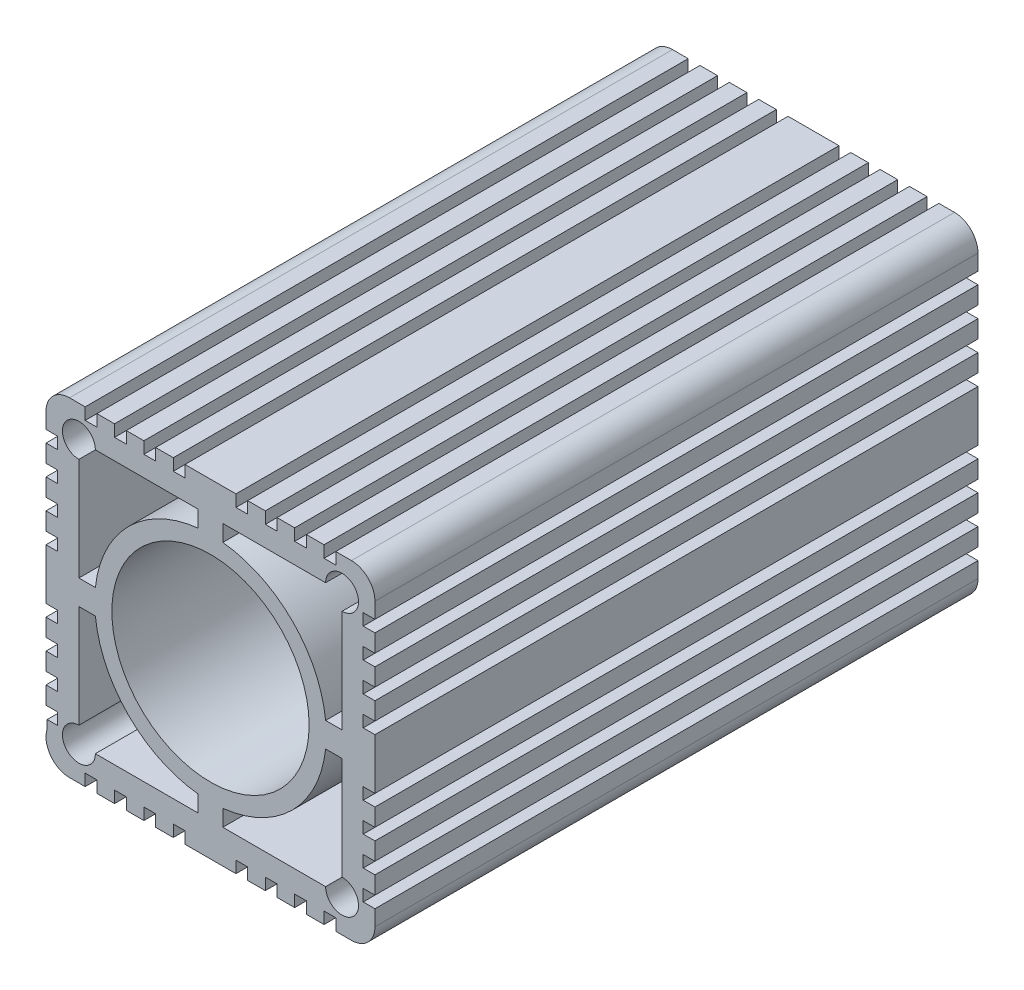
from build123d import *

# Parameters (mm, degrees)
SKETCH3_R           = 8.996543211
BOSS_EXTRUDE1_DEPTH = 55
SKETCH4_W           = 25.72553188
SKETCH4_H           = 15
BOSS_EXTRUDE2_DEPTH = 3
SKETCH5_R           = 1.5
CUT_EXTRUDE1_DEPTH  = 3.5


with BuildPart() as part:
    # Sketch3 → Boss-Extrude1 (new body)
    with BuildSketch(Plane(origin=(0, 0, 0), x_dir=(-1, 0, 0), z_dir=(0, 0, 1))):
        with BuildLine():
            Line((-14.998808917, -10.28846037), (-13.927380346, -10.28846037))
            Line((-13.927380346, -10.28846037), (-13.927380346, -11.359888941))
            Line((-13.927380346, -11.359888941), (-14.998808917, -11.359888941))
            Line((-14.998808917, -11.359888941), (-14.998808917, -12.78846037))
            ThreePointArc((-14.998808917, -12.78846037), (-14.371180591, -14.303689187), (-12.855951774, -14.931317513))
            Line((-12.855951774, -14.931317513), (-11.427380346, -14.931317513))
            Line((-11.427380346, -14.931317513), (-11.427380346, -13.859888941))
            Line((-11.427380346, -13.859888941), (-10.355951774, -13.859888941))
            Line((-10.355951774, -13.859888941), (-10.355951774, -14.931317513))
            Line((-10.355951774, -14.931317513), (-8.748808917, -14.931317513))
            Line((-8.748808917, -14.931317513), (-8.748808917, -13.859888941))
            Line((-8.748808917, -13.859888941), (-7.677380346, -13.859888941))
            Line((-7.677380346, -13.859888941), (-7.677380346, -14.931317513))
            Line((-7.677380346, -14.931317513), (-6.070237488, -14.931317513))
            Line((-6.070237488, -14.931317513), (-6.070237488, -13.859888941))
            Line((-6.070237488, -13.859888941), (-4.998808917, -13.859888941))
            Line((-4.998808917, -13.859888941), (-4.998808917, -14.931317513))
            Line((-4.998808917, -14.931317513), (-3.39166606, -14.931317513))
            Line((-3.39166606, -14.931317513), (-3.39166606, -13.859888941))
            Line((-3.39166606, -13.859888941), (-2.320237488, -13.859888941))
            Line((-2.320237488, -13.859888941), (-2.320237488, -14.931317513))
            Line((-2.320237488, -14.931317513), (2.322619654, -14.931317513))
            Line((2.322619654, -14.931317513), (2.322619654, -13.859888941))
            Line((2.322619654, -13.859888941), (3.394048226, -13.859888941))
            Line((3.394048226, -13.859888941), (3.394048226, -14.931317513))
            Line((3.394048226, -14.931317513), (5.001191083, -14.931317513))
            Line((5.001191083, -14.931317513), (5.001191083, -13.859888941))
            Line((5.001191083, -13.859888941), (6.072619654, -13.859888941))
            Line((6.072619654, -13.859888941), (6.072619654, -14.931317513))
            Line((6.072619654, -14.931317513), (7.679762512, -14.931317513))
            Line((7.679762512, -14.931317513), (7.679762512, -13.859888941))
            Line((7.679762512, -13.859888941), (8.751191083, -13.859888941))
            Line((8.751191083, -13.859888941), (8.751191083, -14.931317513))
            Line((8.751191083, -14.931317513), (10.35833394, -14.931317513))
            Line((10.35833394, -14.931317513), (10.35833394, -13.859888941))
            Line((10.35833394, -13.859888941), (11.429762512, -13.859888941))
            Line((11.429762512, -13.859888941), (11.429762512, -14.931317513))
            Line((11.429762512, -14.931317513), (12.85833394, -14.931317513))
            ThreePointArc((12.85833394, -14.931317513), (14.373562757, -14.303689187), (15.001191083, -12.78846037))
            Line((15.001191083, -12.78846037), (15.001191083, -11.359888941))
            Line((15.001191083, -11.359888941), (13.929762512, -11.359888941))
            Line((13.929762512, -11.359888941), (13.929762512, -10.28846037))
            Line((13.929762512, -10.28846037), (15.001191083, -10.28846037))
            Line((15.001191083, -10.28846037), (15.001191083, -8.681317513))
            Line((15.001191083, -8.681317513), (13.929762512, -8.681317513))
            Line((13.929762512, -8.681317513), (13.929762512, -7.609888941))
            Line((13.929762512, -7.609888941), (15.001191083, -7.609888941))
            Line((15.001191083, -7.609888941), (15.001191083, -6.002746084))
            Line((15.001191083, -6.002746084), (13.929762512, -6.002746084))
            Line((13.929762512, -6.002746084), (13.929762512, -4.931317513))
            Line((13.929762512, -4.931317513), (15.001191083, -4.931317513))
            Line((15.001191083, -4.931317513), (15.001191083, -3.324174656))
            Line((15.001191083, -3.324174656), (13.929762512, -3.324174656))
            Line((13.929762512, -3.324174656), (13.929762512, -2.252746084))
            Line((13.929762512, -2.252746084), (15.001191083, -2.252746084))
            Line((15.001191083, -2.252746084), (15.001191083, 2.390111059))
            Line((15.001191083, 2.390111059), (13.929762512, 2.390111059))
            Line((13.929762512, 2.390111059), (13.929762512, 3.46153963))
            Line((13.929762512, 3.46153963), (15.001191083, 3.46153963))
            Line((15.001191083, 3.46153963), (15.001191083, 5.068682487))
            Line((15.001191083, 5.068682487), (13.929762512, 5.068682487))
            Line((13.929762512, 5.068682487), (13.929762512, 6.140111059))
            Line((13.929762512, 6.140111059), (15.001191083, 6.140111059))
            Line((15.001191083, 6.140111059), (15.001191083, 7.747253916))
            Line((15.001191083, 7.747253916), (13.929762512, 7.747253916))
            Line((13.929762512, 7.747253916), (13.929762512, 8.818682487))
            Line((13.929762512, 8.818682487), (15.001191083, 8.818682487))
            Line((15.001191083, 8.818682487), (15.001191083, 10.425825344))
            Line((15.001191083, 10.425825344), (13.929762512, 10.425825344))
            Line((13.929762512, 10.425825344), (13.929762512, 11.497253916))
            Line((13.929762512, 11.497253916), (14.894048226, 11.497253916))
            Line((14.894048226, 11.497253916), (14.894048226, 12.256718416))
            ThreePointArc((14.894048226, 12.256718416), (14.594081228, 14.182415209), (12.85833394, 15.068682487))
            Line((12.85833394, 15.068682487), (11.429762512, 15.068682487))
            Line((11.429762512, 15.068682487), (11.429762512, 13.997253916))
            Line((11.429762512, 13.997253916), (10.35833394, 13.997253916))
            Line((10.35833394, 13.997253916), (10.35833394, 15.068682487))
            Line((10.35833394, 15.068682487), (8.751191083, 15.068682487))
            Line((8.751191083, 15.068682487), (8.751191083, 13.997253916))
            Line((8.751191083, 13.997253916), (7.679762512, 13.997253916))
            Line((7.679762512, 13.997253916), (7.679762512, 15.068682487))
            Line((7.679762512, 15.068682487), (6.072619654, 15.068682487))
            Line((6.072619654, 15.068682487), (6.072619654, 13.997253916))
            Line((6.072619654, 13.997253916), (5.001191083, 13.997253916))
            Line((5.001191083, 13.997253916), (5.001191083, 15.068682487))
            Line((5.001191083, 15.068682487), (3.394048226, 15.068682487))
            Line((3.394048226, 15.068682487), (3.394048226, 13.997253916))
            Line((3.394048226, 13.997253916), (2.322619654, 13.997253916))
            Line((2.322619654, 13.997253916), (2.322619654, 15.068682487))
            Line((2.322619654, 15.068682487), (-2.320237488, 15.068682487))
            Line((-2.320237488, 15.068682487), (-2.320237488, 13.997253916))
            Line((-2.320237488, 13.997253916), (-3.39166606, 13.997253916))
            Line((-3.39166606, 13.997253916), (-3.39166606, 15.068682487))
            Line((-3.39166606, 15.068682487), (-4.998808917, 15.068682487))
            Line((-4.998808917, 15.068682487), (-4.998808917, 13.997253916))
            Line((-4.998808917, 13.997253916), (-6.070237488, 13.997253916))
            Line((-6.070237488, 13.997253916), (-6.070237488, 15.068682487))
            Line((-6.070237488, 15.068682487), (-7.677380346, 15.068682487))
            Line((-7.677380346, 15.068682487), (-7.677380346, 13.997253916))
            Line((-7.677380346, 13.997253916), (-8.748808917, 13.997253916))
            Line((-8.748808917, 13.997253916), (-8.748808917, 15.068682487))
            Line((-8.748808917, 15.068682487), (-10.355951774, 15.068682487))
            Line((-10.355951774, 15.068682487), (-10.355951774, 13.997253916))
            Line((-10.355951774, 13.997253916), (-11.427380346, 13.997253916))
            Line((-11.427380346, 13.997253916), (-11.427380346, 15.068682487))
            Line((-11.427380346, 15.068682487), (-12.855951774, 15.068682487))
            ThreePointArc((-12.855951774, 15.068682487), (-14.371180591, 14.441054161), (-14.998808917, 12.925825344))
            Line((-14.998808917, 12.925825344), (-14.998808917, 11.497253916))
            Line((-14.998808917, 11.497253916), (-13.927380346, 11.497253916))
            Line((-13.927380346, 11.497253916), (-13.927380346, 10.425825344))
            Line((-13.927380346, 10.425825344), (-14.998808917, 10.425825344))
            Line((-14.998808917, 10.425825344), (-14.998808917, 8.818682487))
            Line((-14.998808917, 8.818682487), (-13.927380346, 8.818682487))
            Line((-13.927380346, 8.818682487), (-13.927380346, 7.747253916))
            Line((-13.927380346, 7.747253916), (-14.998808917, 7.747253916))
            Line((-14.998808917, 7.747253916), (-14.998808917, 6.140111059))
            Line((-14.998808917, 6.140111059), (-13.927380346, 6.140111059))
            Line((-13.927380346, 6.140111059), (-13.927380346, 5.068682487))
            Line((-13.927380346, 5.068682487), (-14.998808917, 5.068682487))
            Line((-14.998808917, 5.068682487), (-14.998808917, 3.46153963))
            Line((-14.998808917, 3.46153963), (-13.927380346, 3.46153963))
            Line((-13.927380346, 3.46153963), (-13.927380346, 2.390111059))
            Line((-13.927380346, 2.390111059), (-14.998808917, 2.390111059))
            Line((-14.998808917, 2.390111059), (-14.998808917, -2.252746084))
            Line((-14.998808917, -2.252746084), (-13.927380346, -2.252746084))
            Line((-13.927380346, -2.252746084), (-13.927380346, -3.324174656))
            Line((-13.927380346, -3.324174656), (-14.998808917, -3.324174656))
            Line((-14.998808917, -3.324174656), (-14.998808917, -4.931317513))
            Line((-14.998808917, -4.931317513), (-13.927380346, -4.931317513))
            Line((-13.927380346, -4.931317513), (-13.927380346, -6.002746084))
            Line((-13.927380346, -6.002746084), (-14.998808917, -6.002746084))
            Line((-14.998808917, -6.002746084), (-14.998808917, -7.609888941))
            Line((-14.998808917, -7.609888941), (-13.927380346, -7.609888941))
            Line((-13.927380346, -7.609888941), (-13.927380346, -8.681317513))
            Line((-13.927380346, -8.681317513), (-14.998808917, -8.681317513))
            Line((-14.998808917, -8.681317513), (-14.998808917, -10.28846037))
        make_face()
        Circle(SKETCH3_R, mode=Mode.SUBTRACT)
        with BuildLine():
            Line((-12, 10.5), (-12, 1.125))
            Line((-12, 1.125), (-10.5, 1.125))
            ThreePointArc((-10.5, 1.125), (-7.467115407, 7.467115407), (-1.125, 10.5))
            Line((-1.125, 10.5), (-1.125, 12))
            Line((-1.125, 12), (-10.5, 12))
            ThreePointArc((-10.5, 12), (-13.060660172, 13.060660172), (-12, 10.5))
        make_face(mode=Mode.SUBTRACT)
        with BuildLine():
            Line((12, -10.5), (12, -1.125))
            Line((12, -1.125), (10.5, -1.125))
            ThreePointArc((10.5, -1.125), (7.467115407, -7.467115407), (1.125, -10.5))
            Line((1.125, -10.5), (1.125, -12))
            Line((1.125, -12), (10.5, -12))
            ThreePointArc((10.5, -12), (13.060660172, -13.060660172), (12, -10.5))
        make_face(mode=Mode.SUBTRACT)
        with BuildLine():
            Line((-10.5, -12), (-1.125, -12))
            Line((-1.125, -12), (-1.125, -10.5))
            ThreePointArc((-1.125, -10.5), (-7.467115407, -7.467115407), (-10.5, -1.125))
            Line((-10.5, -1.125), (-12, -1.125))
            Line((-12, -1.125), (-12, -10.5))
            ThreePointArc((-12, -10.5), (-13.060660172, -13.060660172), (-10.5, -12))
        make_face(mode=Mode.SUBTRACT)
        with BuildLine():
            Line((10.5, 12), (1.125, 12))
            Line((1.125, 12), (1.125, 10.5))
            ThreePointArc((1.125, 10.5), (7.467115407, 7.467115407), (10.5, 1.125))
            Line((10.5, 1.125), (12, 1.125))
            Line((12, 1.125), (12, 10.5))
            ThreePointArc((12, 10.5), (13.060660172, 13.060660172), (10.5, 12))
        make_face(mode=Mode.SUBTRACT)
    extrude(amount=BOSS_EXTRUDE1_DEPTH)

    # Sketch4 → Boss-Extrude2 (add)
    with BuildSketch(Plane.XZ.offset(15.068682487)):
        with Locations((-0.012654457, 9.955577538)):
            Rectangle(SKETCH4_W, SKETCH4_H)
    extrude(amount=-BOSS_EXTRUDE2_DEPTH)

    # Sketch5 → Cut-Extrude1 (cut)
    with BuildSketch(Plane.XZ.offset(15.068682487)):
        with Locations((9.918808917, 12.455577538)):
            Circle(SKETCH5_R)
        with Locations((-9.921191083, 12.455577538)):
            Circle(SKETCH5_R)
    extrude(amount=-CUT_EXTRUDE1_DEPTH, mode=Mode.SUBTRACT)


solid = part.part
